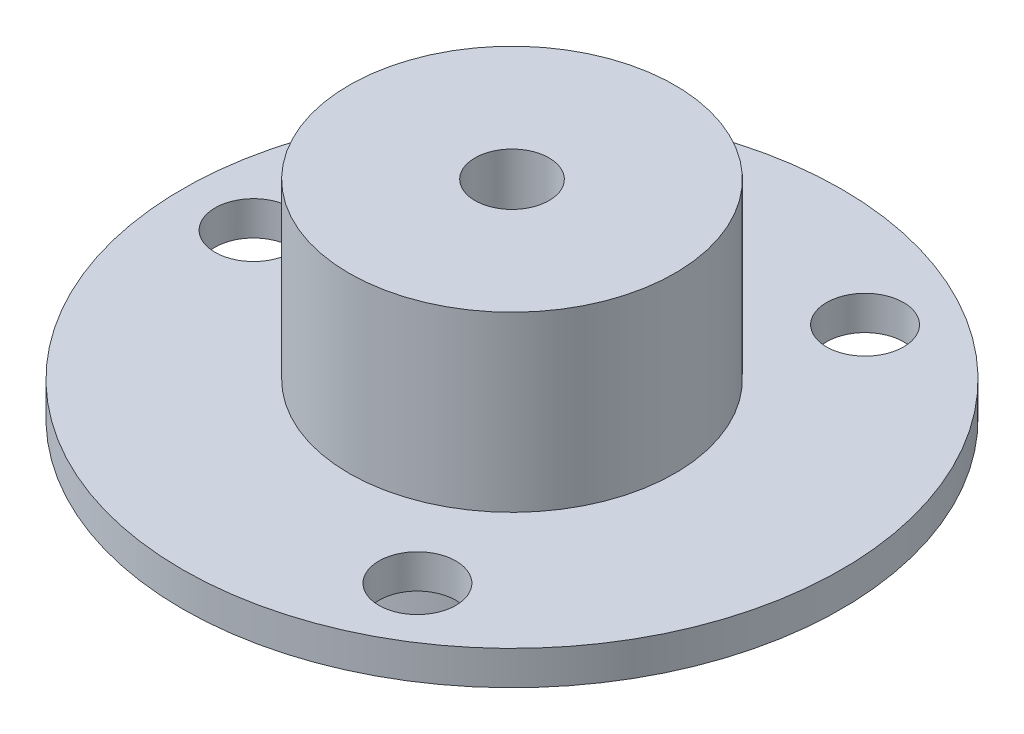
from build123d import *

# Parameters (mm, degrees)
SKETCH1_R             = 11
BOSS_EXTRUDE1_DEPTH   = 19
SKETCH2_R             = 22.25
BOSS_EXTRUDE2_DEPTH   = 2.3
SKETCH4_R             = 2.5
CUT_EXTRUDE1_DEPTH    = 20
SKETCH5_R             = 2.6
CUT_EXTRUDE2_DEPTH    = 15
SKETCH6_R             = 4.5
SKETCH6_R_2           = 2.5
BOSS_EXTRUDE3_DEPTH   = 5
SKETCH7_R             = 0.5
BOSS_EXTRUDE4_DEPTH   = 3
BOSS_EXTRUDE4_2_DEPTH = 3
BOSS_EXTRUDE4_3_DEPTH = 3
BOSS_EXTRUDE4_4_DEPTH = 3
BOSS_EXTRUDE4_5_DEPTH = 3
BOSS_EXTRUDE4_6_DEPTH = 3


with BuildPart() as part:
    # Sketch1 → Boss-Extrude1 (new body)
    with BuildSketch(Plane(origin=(0, 0, 0), x_dir=(1, 0, 0), z_dir=(0, 1, 0))):
        Circle(SKETCH1_R)
    extrude(amount=BOSS_EXTRUDE1_DEPTH)

    # Sketch2 → Boss-Extrude2 (add)
    with BuildSketch(Plane(origin=(0, 5, 0), x_dir=(1, 0, 0), z_dir=(0, 1, 0))):
        Circle(SKETCH2_R)
    extrude(amount=BOSS_EXTRUDE2_DEPTH)

    # Sketch4 → Cut-Extrude1 (cut, through all)
    with BuildSketch(Plane.XZ):
        Circle(SKETCH4_R)
    extrude(amount=-CUT_EXTRUDE1_DEPTH, mode=Mode.SUBTRACT)

    # Sketch5 → Cut-Extrude2 (cut, through all)
    with BuildSketch(Plane.XZ.offset(-5)):
        with Locations((-17.45, 0)):
            Circle(SKETCH5_R)
        with Locations((8.725, 15.112143296)):
            Circle(SKETCH5_R)
        with Locations((8.725, -15.112143296)):
            Circle(SKETCH5_R)
    extrude(amount=-CUT_EXTRUDE2_DEPTH, mode=Mode.SUBTRACT)

    # Sketch6 → Boss-Extrude3 (add)
    with BuildSketch(Plane.XZ):
        Circle(SKETCH6_R)
        Circle(SKETCH6_R_2, mode=Mode.SUBTRACT)
    extrude(amount=BOSS_EXTRUDE3_DEPTH)


with BuildPart() as body_2:
    # Sketch7 → Boss-Extrude4 (new body)
    with BuildSketch(Plane.XZ.offset(5)):
        with Locations((3.103518322, 1.618077263)):
            Circle(SKETCH7_R)
    extrude(amount=BOSS_EXTRUDE4_DEPTH)


with BuildPart() as body_3:
    # Sketch7 → Boss-Extrude4 2 (new body)
    with BuildSketch(Plane.XZ.offset(5)):
        with Locations((3.5, 0)):
            Circle(SKETCH7_R)
    extrude(amount=BOSS_EXTRUDE4_2_DEPTH)


with BuildPart() as body_4:
    # Sketch7 → Boss-Extrude4 3 (new body)
    with BuildSketch(Plane.XZ.offset(5)):
        with Locations((3.089895924, -1.643941355)):
            Circle(SKETCH7_R)
    extrude(amount=BOSS_EXTRUDE4_3_DEPTH)


with BuildPart() as body_5:
    # Sketch7 → Boss-Extrude4 4 (new body)
    with BuildSketch(Plane.XZ.offset(5)):
        with Locations((-3.089895924, -1.643941355)):
            Circle(SKETCH7_R)
    extrude(amount=BOSS_EXTRUDE4_4_DEPTH)


with BuildPart() as body_6:
    # Sketch7 → Boss-Extrude4 5 (new body)
    with BuildSketch(Plane.XZ.offset(5)):
        with Locations((-3.5, 0)):
            Circle(SKETCH7_R)
    extrude(amount=BOSS_EXTRUDE4_5_DEPTH)


with BuildPart() as body_7:
    # Sketch7 → Boss-Extrude4 6 (new body)
    with BuildSketch(Plane.XZ.offset(5)):
        with Locations((-3.103518322, 1.618077263)):
            Circle(SKETCH7_R)
    extrude(amount=BOSS_EXTRUDE4_6_DEPTH)


solid = Compound([part.part, body_2.part, body_3.part, body_4.part, body_5.part, body_6.part, body_7.part])
